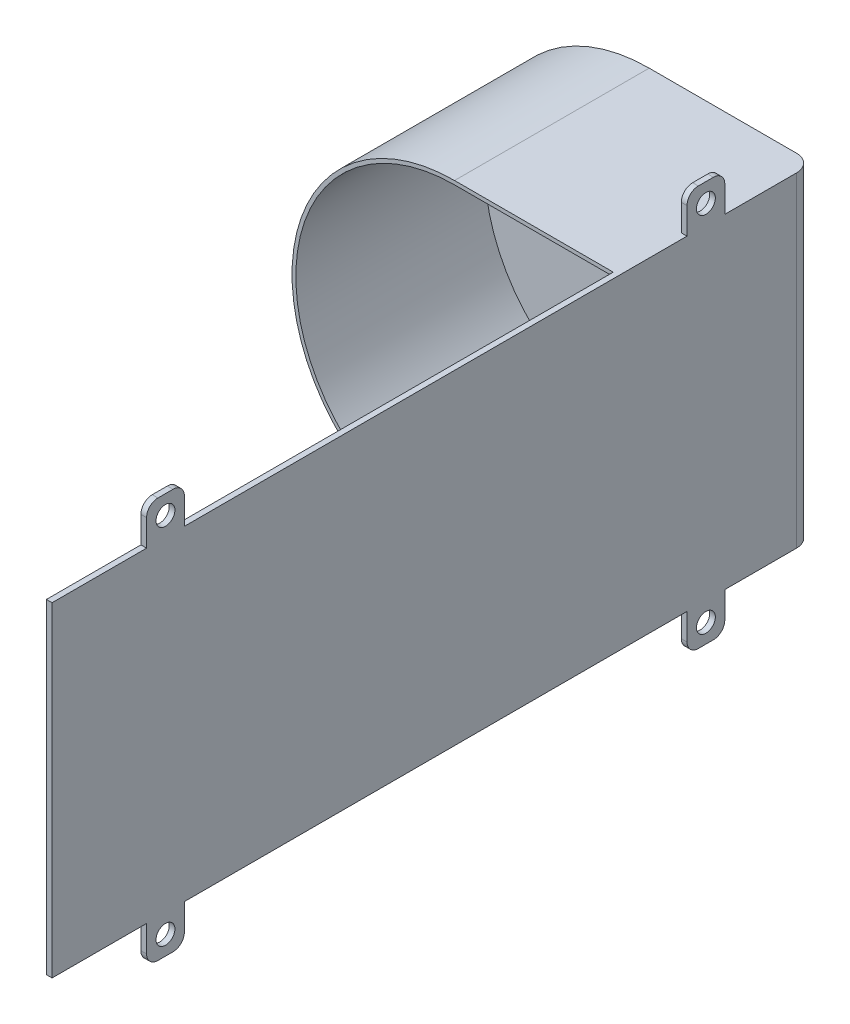
from build123d import *

# Parameters (mm, degrees)
DODANIE_WYCI_GNI_CIE1_DEPTH = 1.5
SZKIC2_W                    = 1.5
SZKIC2_H                    = 86
DODANIE_WYCI_GNI_CIE2_DEPTH = 200
DODANIE_WYCI_GNI_CIE3_DEPTH = 50
ZAOKR_GLENIE1_R             = 3
ZAOKR_GLENIE2_R             = 4.5
DODANIE_WYCI_GNI_CIE4_DEPTH = 1.5
SZKIC6_R                    = 2.5
WYTNIJ_WYCI_GNI_CIE1_DEPTH  = 2.5


with BuildPart() as part:
    # Szkic1 → Dodanie-wyciągnięcie1 (new body)
    with BuildSketch(Plane.XY):
        with BuildLine():
            Line((-0.25, -43), (43.25, -43))
            Line((43.25, -43), (43.25, 43))
            Line((43.25, 43), (-0.25, 43))
            ThreePointArc((-0.25, 43), (-43.25, 0), (-0.25, -43))
        make_face()
    extrude(amount=DODANIE_WYCI_GNI_CIE1_DEPTH)

    # Szkic2 → Dodanie-wyciągnięcie2 (add)
    with BuildSketch(Plane.XY.offset(1.5)):
        with Locations((42.5, 0)):
            Rectangle(SZKIC2_W, SZKIC2_H)
    extrude(amount=DODANIE_WYCI_GNI_CIE2_DEPTH)

    # Szkic4 → Dodanie-wyciągnięcie3 (add)
    with BuildSketch(Plane.XY.offset(1.5)):
        with BuildLine():
            Line((-0.25, -43), (41.75, -43))
            Line((41.75, -43), (41.75, -42))
            Line((41.75, -42), (-0.25, -42))
            ThreePointArc((-0.25, -42), (-42.25, 0), (-0.25, 42))
            Line((-0.25, 42), (41.75, 42))
            Line((41.75, 42), (41.75, 43))
            Line((41.75, 43), (-0.25, 43))
            ThreePointArc((-0.25, 43), (-43.25, 0), (-0.25, -43))
        make_face()
    extrude(amount=DODANIE_WYCI_GNI_CIE3_DEPTH)

    # Zaokrąglenie1
    zaokr_glenie1_edges = [part.edges().sort_by_distance(p)[0] for p in [
        (41.75, 0, 1.5),
    ]]
    fillet(zaokr_glenie1_edges, radius=ZAOKR_GLENIE1_R)

    # Zaokrąglenie2
    zaokr_glenie2_edges = [part.edges().sort_by_distance(p)[0] for p in [
        (43.25, 0, 0),
    ]]
    fillet(zaokr_glenie2_edges, radius=ZAOKR_GLENIE2_R)

    # Szkic5 → Dodanie-wyciągnięcie4 (add)
    with BuildSketch(Plane.ZY.offset(-41.75)):
        with BuildLine():
            Line((166.5, 43), (176.5, 43))
            Line((176.5, 43), (176.5, 50))
            ThreePointArc((176.5, 50), (175.621320344, 52.121320344), (173.5, 53))
            Line((173.5, 53), (169.5, 53))
            ThreePointArc((169.5, 53), (167.378679656, 52.121320344), (166.5, 50))
            Line((166.5, 50), (166.5, 43))
        make_face()
        with BuildLine():
            Line((166.5, -50), (166.5, -43))
            Line((166.5, -43), (176.5, -43))
            Line((176.5, -43), (176.5, -50))
            ThreePointArc((176.5, -50), (175.621320344, -52.121320344), (173.5, -53))
            Line((173.5, -53), (169.5, -53))
            ThreePointArc((169.5, -53), (167.378679656, -52.121320344), (166.5, -50))
        make_face()
    dodanie_wyci_gni_cie4 = extrude(amount=-DODANIE_WYCI_GNI_CIE4_DEPTH)

    # Szkic6 → Wytnij-wyciągnięcie1 (cut, through all)
    with BuildSketch(Plane.ZY.offset(-41.75)):
        with Locations((171.5, 48)):
            Circle(SZKIC6_R)
        with Locations((171.5, -48)):
            Circle(SZKIC6_R)
    wytnij_wyci_gni_cie1 = extrude(amount=-WYTNIJ_WYCI_GNI_CIE1_DEPTH, mode=Mode.SUBTRACT)

    # Lustro1: Dodanie-wyciągnięcie4, Wytnij-wyciągnięcie1 across plane
    add(dodanie_wyci_gni_cie4.mirror(Plane.XY.offset(100)))
    add(wytnij_wyci_gni_cie1.mirror(Plane.XY.offset(100)), mode=Mode.SUBTRACT)


solid = part.part
